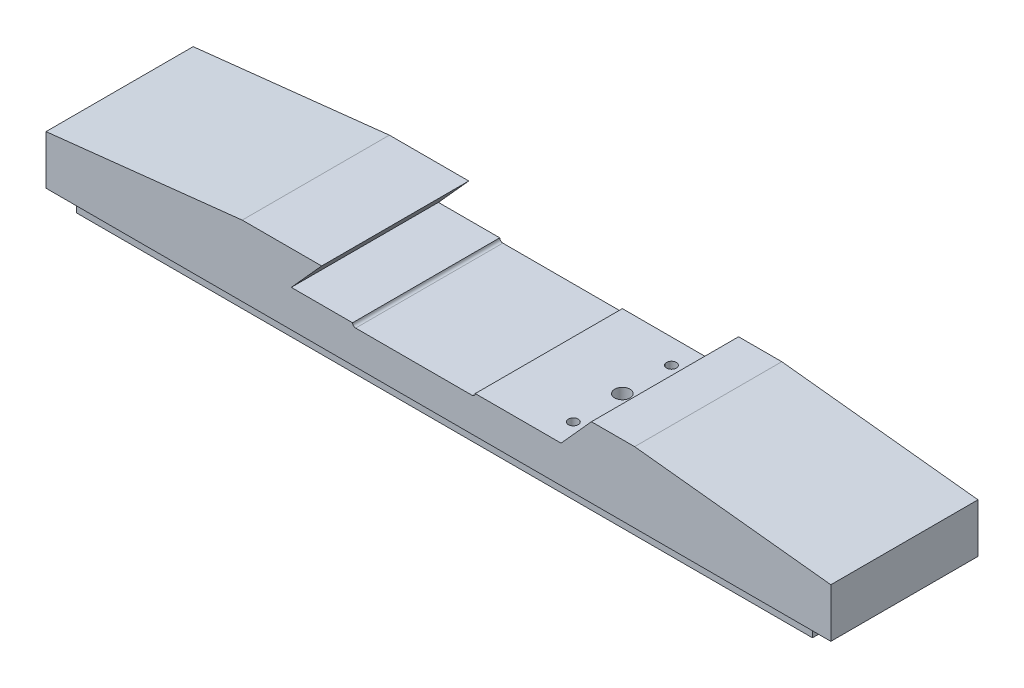
from build123d import *

# Parameters (mm, degrees)
BOSS_EXTRUDE1_DEPTH         = 76.2
BOSS_EXTRUDE2_DEPTH         = 381
F_1_4_20_TAPPED_HOLE3_D     = 5.1054
F_1_4_20_TAPPED_HOLE3_DEPTH = 19.05
F_1_4_20_TAPPED_HOLE3_TIP   = 1.533816902
F_1_4_20_TAPPED_HOLE2_D     = 5.1054
F_1_4_20_TAPPED_HOLE2_DEPTH = 19.05
F_1_4_20_TAPPED_HOLE2_TIP   = 1.533816902
F_3_8_16_TAPPED_HOLE1_D     = 7.9375
F_3_8_16_TAPPED_HOLE1_DEPTH = 26.924
F_3_8_16_TAPPED_HOLE1_TIP   = 2.384665582
F_1_4_20_TAPPED_HOLE1_D     = 5.1054
F_1_4_20_TAPPED_HOLE1_DEPTH = 17.4625
F_1_4_20_TAPPED_HOLE1_TIP   = 1.533816902
CHAMFER1_SIZE               = 20.492049699
CHAMFER1_SIZE2              = 2.998111049


with BuildPart() as part:
    # Sketch1 → Boss-Extrude1 (new body)
    with BuildSketch(Plane(origin=(0, 0, -76.2), x_dir=(-1, 0, 0), z_dir=(0, 0, -1))):
        with BuildLine():
            Line((0, 0), (0, 25.4))
            Line((0, 25.4), (-101.6, 36.5125))
            Line((-101.6, 36.5125), (-142.723305624, 36.5125))
            Line((-142.723305624, 36.5125), (-127, 19.05))
            Line((-127, 19.05), (-158.75, 19.05))
            ThreePointArc((-158.75, 19.05), (-159.214967985, 17.927467985), (-160.3375, 17.4625))
            Line((-160.3375, 17.4625), (-220.6625, 17.4625))
            ThreePointArc((-220.6625, 17.4625), (-221.785032015, 17.927467985), (-222.25, 19.05))
            Line((-222.25, 19.05), (-266.7, 19.05))
            Line((-266.7, 19.05), (-284.429433488, 38.740530712))
            Line((-284.429433488, 38.740530712), (-406.4, 25.4))
            Line((-406.4, 25.4), (-406.4, 0))
            Line((-406.4, 0), (0, 0))
        make_face()
    extrude(amount=-BOSS_EXTRUDE1_DEPTH)

    # Sketch2 → Boss-Extrude2 (add)
    with BuildSketch(Plane(origin=(0, 0, 0), x_dir=(0, -1, 0), z_dir=(-1, 0, 0))):
        Polygon((0, -25.4), (0, -50.8), (9.525, -50.8), (9.525, -60.325), (19.05, -60.325), (19.05, -15.875), (9.525, -15.875), (9.525, -25.4), align=None)
    extrude(amount=-BOSS_EXTRUDE2_DEPTH)

    # 1/4-20 Tapped Hole3
    with Locations(Plane(origin=(0, 0, 0), x_dir=(-1, 0, 0), z_dir=(0, -1, 0))):
        with Locations((-393.7, 65.0875), (-393.7, 11.1125)):
            Hole(F_1_4_20_TAPPED_HOLE3_D / 2, depth=F_1_4_20_TAPPED_HOLE3_DEPTH)
            with Locations((0, 0, -(F_1_4_20_TAPPED_HOLE3_DEPTH + F_1_4_20_TAPPED_HOLE3_TIP / 2))):  # 118° drill point
                Cone(0, F_1_4_20_TAPPED_HOLE3_D / 2, F_1_4_20_TAPPED_HOLE3_TIP, mode=Mode.SUBTRACT)

    # 1/4-20 Tapped Hole2
    with Locations(Plane(origin=(0, 0, -76.2), x_dir=(-1, 0, 0), z_dir=(0, 0, -1))):
        with Locations((-139.7, 9.525), (-241.3, 9.525)):
            Hole(F_1_4_20_TAPPED_HOLE2_D / 2, depth=F_1_4_20_TAPPED_HOLE2_DEPTH)
            with Locations((0, 0, -(F_1_4_20_TAPPED_HOLE2_DEPTH + F_1_4_20_TAPPED_HOLE2_TIP / 2))):  # 118° drill point
                Cone(0, F_1_4_20_TAPPED_HOLE2_D / 2, F_1_4_20_TAPPED_HOLE2_TIP, mode=Mode.SUBTRACT)

    # 3/8-16 Tapped Hole1
    with Locations(Plane(origin=(0, 19.05, 0), x_dir=(1, 0, 0), z_dir=(0, 1, 0))):
        with Locations((260.35, 38.1)):
            Hole(F_3_8_16_TAPPED_HOLE1_D / 2, depth=F_3_8_16_TAPPED_HOLE1_DEPTH)
            with Locations((0, 0, -(F_3_8_16_TAPPED_HOLE1_DEPTH + F_3_8_16_TAPPED_HOLE1_TIP / 2))):  # 118° drill point
                Cone(0, F_3_8_16_TAPPED_HOLE1_D / 2, F_3_8_16_TAPPED_HOLE1_TIP, mode=Mode.SUBTRACT)

    # 1/4-20 Tapped Hole1
    with Locations(Plane(origin=(0, 19.05, 0), x_dir=(1, 0, 0), z_dir=(0, 1, 0))):
        with Locations((260.35, 12.7), (260.35, 63.5)):
            Hole(F_1_4_20_TAPPED_HOLE1_D / 2, depth=F_1_4_20_TAPPED_HOLE1_DEPTH)
            with Locations((0, 0, -(F_1_4_20_TAPPED_HOLE1_DEPTH + F_1_4_20_TAPPED_HOLE1_TIP / 2))):  # 118° drill point
                Cone(0, F_1_4_20_TAPPED_HOLE1_D / 2, F_1_4_20_TAPPED_HOLE1_TIP, mode=Mode.SUBTRACT)

    # Chamfer1
    chamfer1_edges = [part.edges().sort_by_distance(p)[0] for p in [
        (284.429433488, 38.740530712, -38.1),
    ]]
    chamfer1_side = [part.faces().sort_by_distance(p)[0] for p in [
        (345.414716744, 32.070265356, -38.1),
    ]]
    chamfer(chamfer1_edges, length=CHAMFER1_SIZE, length2=CHAMFER1_SIZE2, reference=chamfer1_side[0])


solid = part.part
